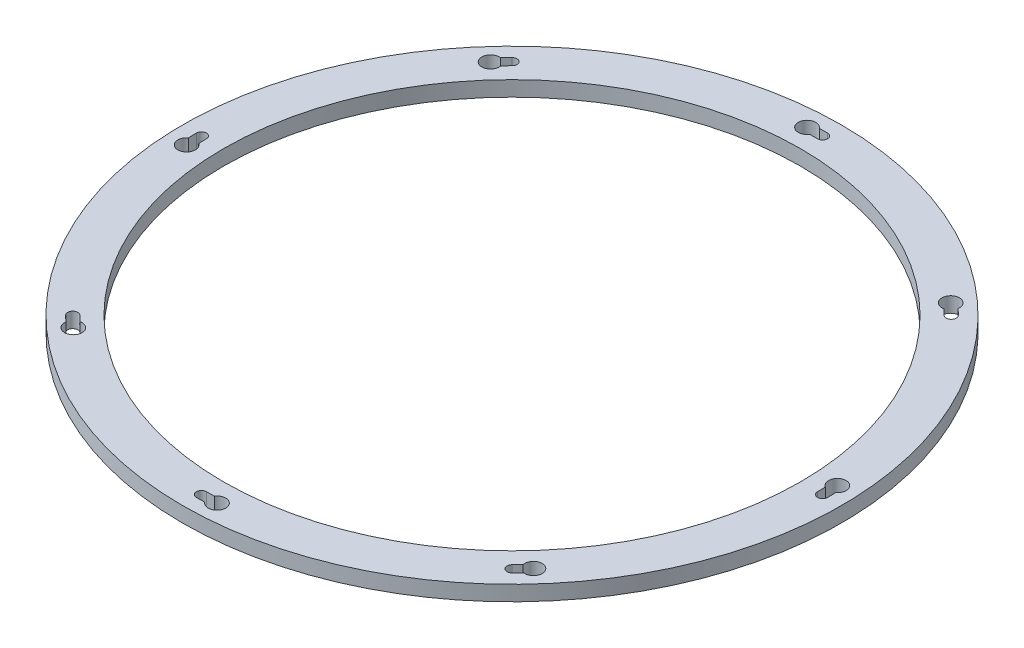
from build123d import *

# Parameters (mm, degrees)
SKETCH1_R            = 217
SKETCH1_R_2          = 190
MAINRING_DEPTH       = 10
M6_CLEARANCE_HOLE1_D = 6.6
HOLEPATTERN_COUNT    = 8
CUT_EXTRUDE1_DEPTH   = 11
CIRPATTERN1_COUNT    = 8


with BuildPart() as part:
    # Sketch1 → MainRing (new body)
    with BuildSketch(Plane(origin=(0, 0, 0), x_dir=(1, 0, 0), z_dir=(0, 1, 0))):
        Circle(SKETCH1_R)
        Circle(SKETCH1_R_2, mode=Mode.SUBTRACT)
    extrude(amount=MAINRING_DEPTH)

    # M6 Clearance Hole1 (through all)
    with Locations(Plane(origin=(0, 0, 0), x_dir=(-1, 0, 0), z_dir=(0, -1, 0))):
        with Locations((0, -204.5)):
            m6_clearance_hole1 = Hole(M6_CLEARANCE_HOLE1_D / 2)

    # HolePattern: M6 Clearance Hole1 ×8 about axis
    holepattern_axis = Axis((0, 0, 0), (0, 1, 0))
    for i in range(1, HOLEPATTERN_COUNT):
        add(m6_clearance_hole1.rotate(holepattern_axis, i * 360 / HOLEPATTERN_COUNT), mode=Mode.SUBTRACT)

    # Sketch5 → Cut-Extrude1 (cut, through all)
    with BuildSketch(Plane.XZ):
        with BuildLine():
            ThreePointArc((201.13360859, -5.168316504), (204.040552386, -15.742991514), (207.729432581, -5.415056739))
            ThreePointArc((207.729432581, -5.415056739), (207.782357396, -2.707758263), (207.8, 0))
            ThreePointArc((207.8, 0), (204.5, -3.3), (201.2, 0))
            ThreePointArc((201.2, 0), (201.183401463, -2.584371456), (201.13360859, -5.168316504))
        make_face()
    cut_extrude1 = extrude(amount=-CUT_EXTRUDE1_DEPTH, mode=Mode.SUBTRACT)

    # CirPattern1: Cut-Extrude1 ×8 about axis
    cirpattern1_axis = Axis((0, 0, 0), (0, 1, 0))
    for i in range(1, CIRPATTERN1_COUNT):
        add(cut_extrude1.rotate(cirpattern1_axis, i * 360 / CIRPATTERN1_COUNT), mode=Mode.SUBTRACT)


solid = part.part
